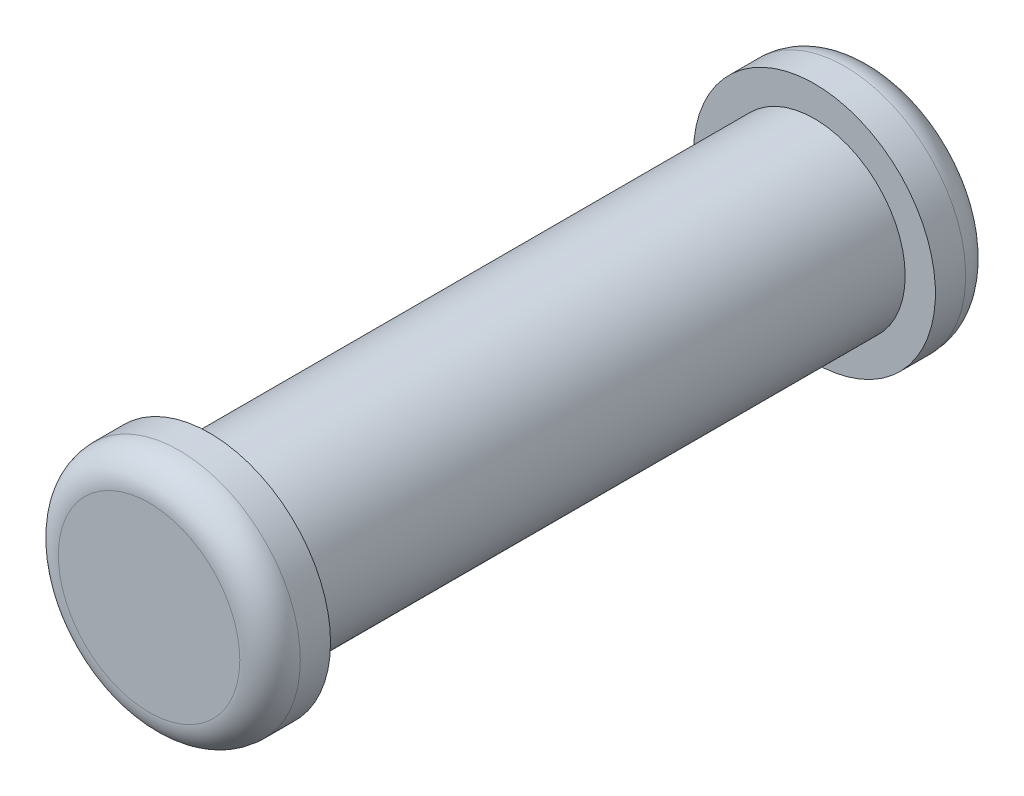
from build123d import *

# Parameters (mm, degrees)
SKETCH1_R           = 1.5
BOSS_EXTRUDE1_DEPTH = 10
SKETCH2_R           = 2
BOSS_EXTRUDE2_DEPTH = 1
SKETCH3_R           = 2
BOSS_EXTRUDE3_DEPTH = 1
FILLET1_R           = 0.5


with BuildPart() as part:
    # Sketch1 → Boss-Extrude1 (new body)
    with BuildSketch(Plane.XY):
        Circle(SKETCH1_R)
    extrude(amount=BOSS_EXTRUDE1_DEPTH)

    # Sketch2 → Boss-Extrude2 (add)
    with BuildSketch(Plane(origin=(0, 0, 0), x_dir=(-1, 0, 0), z_dir=(0, 0, -1))):
        Circle(SKETCH2_R)
    extrude(amount=BOSS_EXTRUDE2_DEPTH)

    # Sketch3 → Boss-Extrude3 (add)
    with BuildSketch(Plane.XY.offset(10)):
        Circle(SKETCH3_R)
    extrude(amount=BOSS_EXTRUDE3_DEPTH)

    # Fillet1
    fillet1_edges = [part.edges().sort_by_distance(p)[0] for p in [
        (-2, 0, 11),
        (2, 0, -1),
    ]]
    fillet(fillet1_edges, radius=FILLET1_R)


solid = part.part
